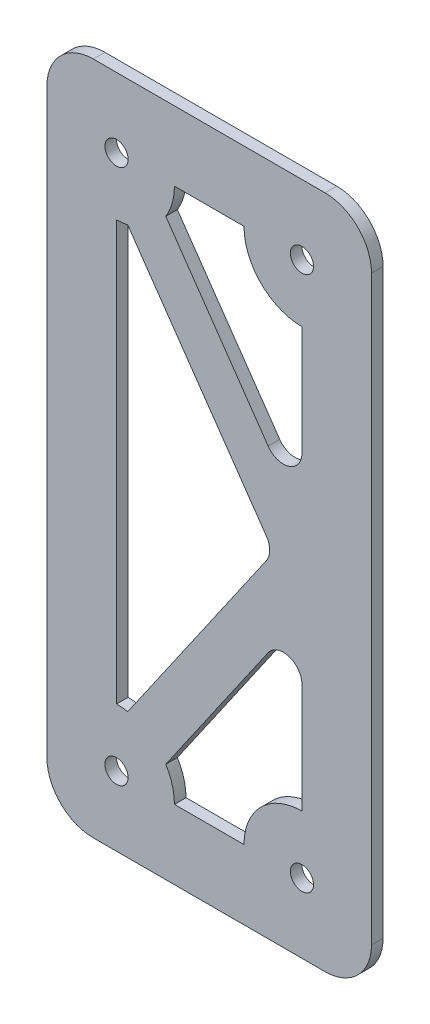
from build123d import *

# Parameters (mm, degrees)
SKETCH1_W           = 88.9
SKETCH1_H           = 184.762458854
SKETCH1_R           = 3.175
BOSS_EXTRUDE1_DEPTH = 3.175
FILLET1_R           = 5.08
FILLET2_R           = 12.7


with BuildPart() as part:
    # Sketch1 → Boss-Extrude1 (new body)
    with BuildSketch(Plane.XY):
        with Locations((1623.410721097, -4179.866189559)):
            Rectangle(SKETCH1_W, SKETCH1_H)
        with Locations((1598.010721097, -4106.534960132)):
            Circle(SKETCH1_R, mode=Mode.SUBTRACT)
        with BuildLine():
            Line((1648.810721097, -4168.715160172), (1611.515942217, -4114.879097445))
            ThreePointArc((1611.515942217, -4114.879097445), (1613.281788681, -4110.872023639), (1613.885721097, -4106.534960132))
            Line((1613.885721097, -4106.534960132), (1632.935721097, -4106.534960132))
            ThreePointArc((1632.935721097, -4106.534960132), (1637.585400946, -4117.760280283), (1648.810721097, -4122.409960132))
            Line((1648.810721097, -4122.409960132), (1648.810721097, -4168.715160172))
        make_face(mode=Mode.SUBTRACT)
        with BuildLine():
            ThreePointArc((1598.010721097, -4122.409960132), (1599.550748635, -4122.335084821), (1601.076248923, -4122.111165194))
            Line((1601.076248923, -4122.111165194), (1641.085877299, -4179.866189559))
            Line((1641.085877299, -4179.866189559), (1601.076248923, -4237.621213923))
            ThreePointArc((1601.076248923, -4237.621213923), (1599.550748635, -4237.397294297), (1598.010721097, -4237.322418986))
            Line((1598.010721097, -4237.322418986), (1598.010721097, -4122.409960132))
        make_face(mode=Mode.SUBTRACT)
        with BuildLine():
            ThreePointArc((1613.885721097, -4253.197418986), (1613.281788681, -4248.860355479), (1611.515942217, -4244.853281672))
            Line((1611.515942217, -4244.853281672), (1648.810721097, -4191.017218946))
            Line((1648.810721097, -4191.017218946), (1648.810721097, -4237.322418986))
            ThreePointArc((1648.810721097, -4237.322418986), (1637.585400946, -4241.972098834), (1632.935721097, -4253.197418986))
            Line((1632.935721097, -4253.197418986), (1613.885721097, -4253.197418986))
        make_face(mode=Mode.SUBTRACT)
        with Locations((1598.010721097, -4253.197418986)):
            Circle(SKETCH1_R, mode=Mode.SUBTRACT)
        with Locations((1648.810721097, -4106.534960132)):
            Circle(SKETCH1_R, mode=Mode.SUBTRACT)
        with Locations((1648.810721097, -4253.197418986)):
            Circle(SKETCH1_R, mode=Mode.SUBTRACT)
    extrude(amount=BOSS_EXTRUDE1_DEPTH)

    # Fillet1
    fillet1_edges = [part.edges().sort_by_distance(p)[0] for p in [
        (1648.810721097, -4191.017218946, 1.5875),
        (1641.085877299, -4179.866189559, 1.5875),
        (1648.810721097, -4168.715160172, 1.5875),
    ]]
    fillet(fillet1_edges, radius=FILLET1_R)

    # Fillet2
    fillet2_edges = [part.edges().sort_by_distance(p)[0] for p in [
        (1667.860721097, -4272.247418986, 1.5875),
        (1578.960721097, -4272.247418986, 1.5875),
        (1578.960721097, -4087.484960132, 1.5875),
        (1667.860721097, -4087.484960132, 1.5875),
    ]]
    fillet(fillet2_edges, radius=FILLET2_R)


solid = part.part
